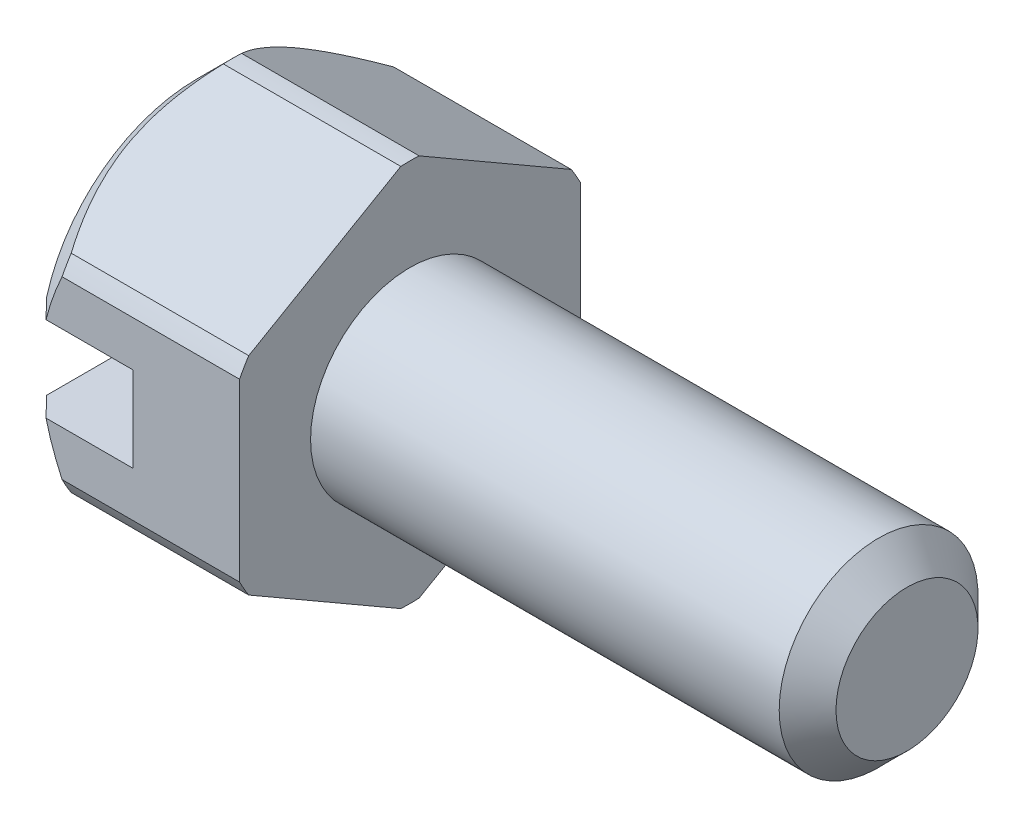
from build123d import *

# Parameters (mm, degrees)
CUT_EXTRUDE_2_DEPTH = 1.5
CHAMFER_1_SIZE      = 0.5
CUT_EXTRUDE_3_DEPTH = 4


with BuildPart() as part:
    # Эскиз1 → Повернуть1 (revolve)
    with BuildSketch(Plane.XY):
        Polygon((0, 0), (0, 2.7), (3, 2.7), (3, 1.4), (9.6, 1.4), (10, 1), (10, 0), align=None)
    revolve(axis=Axis((-1.2940953, 0, 0), (1, 0, 0)))

    # Эскиз2 → Вырез-Вытянуть2 (cut)
    with BuildSketch(Plane.ZY):
        with BuildLine():
            Line((2.632489316, 0.6), (-2.632489316, 0.6))
            ThreePointArc((-2.632489316, 0.6), (-2.7, 0), (-2.632489316, -0.6))
            Line((-2.632489316, -0.6), (2.632489316, -0.6))
            ThreePointArc((2.632489316, -0.6), (2.683069246, -0.301893066), (2.7, 0))
            ThreePointArc((2.7, 0), (2.683069246, 0.301893066), (2.632489316, 0.6))
        make_face()
    extrude(amount=-CUT_EXTRUDE_2_DEPTH, mode=Mode.SUBTRACT)

    # Фаска1
    chamfer_1_edges = [part.edges().sort_by_distance(p)[0] for p in [
        (0, -2.7, 0),
        (0, 2.110687092, 1.683745824),
    ]]
    chamfer(chamfer_1_edges, length=CHAMFER_1_SIZE)

    # Эскиз4 → Вырез-Вытянуть3 (cut, through all)
    with BuildSketch(Plane(origin=(3, 0, 0), x_dir=(0, 0, -1), z_dir=(1, 0, 0))):
        with BuildLine():
            ThreePointArc((2.271214264, 1.459995125), (1.35, 2.33826859), (0.128785736, 2.696926813))
            Line((0.128785736, 2.696926813), (2.271214264, 1.459995125))
        make_face()
        with BuildLine():
            Line((-2.271214264, 1.459995125), (-0.128785736, 2.696926813))
            ThreePointArc((-0.128785736, 2.696926813), (-1.35, 2.33826859), (-2.271214264, 1.459995125))
        make_face()
        with BuildLine():
            Line((-2.4, -1.236931688), (-2.4, 1.236931688))
            ThreePointArc((-2.4, 1.236931688), (-2.7, 0), (-2.4, -1.236931688))
        make_face()
        with BuildLine():
            Line((-0.128785736, -2.696926813), (-2.271214264, -1.459995125))
            ThreePointArc((-2.271214264, -1.459995125), (-1.35, -2.33826859), (-0.128785736, -2.696926813))
        make_face()
        with BuildLine():
            ThreePointArc((0.128785736, -2.696926813), (1.35, -2.33826859), (2.271214264, -1.459995125))
            Line((2.271214264, -1.459995125), (0.128785736, -2.696926813))
        make_face()
        with BuildLine():
            ThreePointArc((2.7, 0), (2.623928353, 0.636396103), (2.4, 1.236931688))
            Line((2.4, 1.236931688), (2.4, -1.236931688))
            ThreePointArc((2.4, -1.236931688), (2.623928353, -0.636396103), (2.7, 0))
        make_face()
    extrude(amount=-CUT_EXTRUDE_3_DEPTH, mode=Mode.SUBTRACT)


solid = part.part
